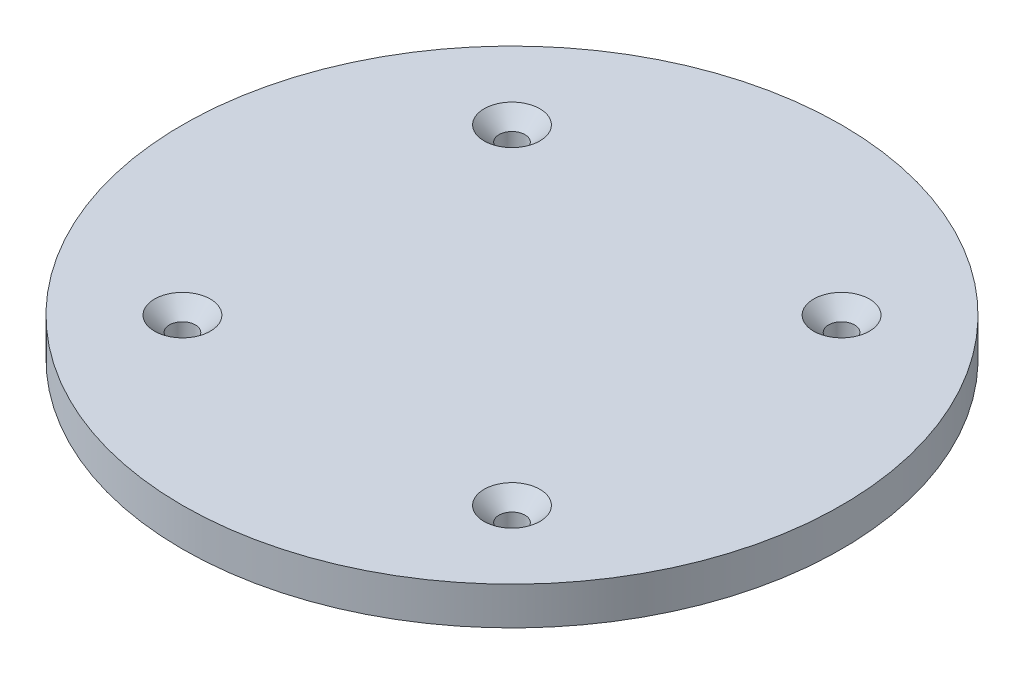
from build123d import *

# Parameters (mm, degrees)
SKETCH1_R           = 50.8
SKETCH1_R_2         = 2
BOSS_EXTRUDE1_DEPTH = 5.842
CHAMFER1_SIZE       = 2.3


with BuildPart() as part:
    # Sketch1 → Boss-Extrude1 (new body)
    with BuildSketch(Plane(origin=(0, 0, 0), x_dir=(1, 0, 0), z_dir=(0, 1, 0))):
        Circle(SKETCH1_R)
        with Locations((-25.4, 25.4)):
            Circle(SKETCH1_R_2, mode=Mode.SUBTRACT)
        with Locations((25.4, 25.4)):
            Circle(SKETCH1_R_2, mode=Mode.SUBTRACT)
        with Locations((25.4, -25.4)):
            Circle(SKETCH1_R_2, mode=Mode.SUBTRACT)
        with Locations((-25.4, -25.4)):
            Circle(SKETCH1_R_2, mode=Mode.SUBTRACT)
    extrude(amount=BOSS_EXTRUDE1_DEPTH)

    # Chamfer1
    chamfer1_edges = [part.edges().sort_by_distance(p)[0] for p in [
        (23.4, 5.842, -25.4),
        (23.4, 5.842, 25.4),
        (-27.4, 5.842, -25.4),
        (-27.4, 5.842, 25.4),
    ]]
    chamfer(chamfer1_edges, length=CHAMFER1_SIZE)


solid = part.part
